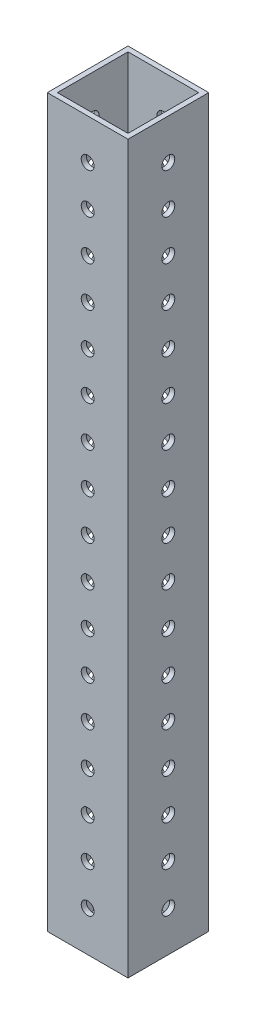
from build123d import *

# Parameters (mm, degrees)
SKETCH1_W           = 25.4
SKETCH1_H           = 25.4
SKETCH1_W_2         = 22.225
SKETCH1_H_2         = 22.225
BOSS_EXTRUDE1_DEPTH = 228.6
SKETCH2_R           = 2.0193
CUT_EXTRUDE1_DEPTH  = 26.4
SKETCH3_R           = 2.0193
CUT_EXTRUDE2_DEPTH  = 26.4


with BuildPart() as part:
    # Sketch1 → Boss-Extrude1 (new body)
    with BuildSketch(Plane(origin=(0, 0, 0), x_dir=(1, 0, 0), z_dir=(0, 1, 0))):
        with Locations((12.7, 12.7)):
            Rectangle(SKETCH1_W, SKETCH1_H)
        with Locations((12.7, 12.7)):
            Rectangle(SKETCH1_W_2, SKETCH1_H_2, mode=Mode.SUBTRACT)
    extrude(amount=BOSS_EXTRUDE1_DEPTH)

    # Sketch2 → Cut-Extrude1 (cut, through all)
    with BuildSketch(Plane.XY):
        with Locations((12.7, 12.7)):
            Circle(SKETCH2_R)
        with Locations((12.7, 25.4)):
            Circle(SKETCH2_R)
        with Locations((12.7, 38.1)):
            Circle(SKETCH2_R)
        with Locations((12.7, 50.8)):
            Circle(SKETCH2_R)
        with Locations((12.7, 63.5)):
            Circle(SKETCH2_R)
        with Locations((12.7, 76.2)):
            Circle(SKETCH2_R)
        with Locations((12.7, 88.9)):
            Circle(SKETCH2_R)
        with Locations((12.7, 101.6)):
            Circle(SKETCH2_R)
        with Locations((12.7, 114.3)):
            Circle(SKETCH2_R)
        with Locations((12.7, 127)):
            Circle(SKETCH2_R)
        with Locations((12.7, 139.7)):
            Circle(SKETCH2_R)
        with Locations((12.7, 152.4)):
            Circle(SKETCH2_R)
        with Locations((12.7, 165.1)):
            Circle(SKETCH2_R)
        with Locations((12.7, 177.8)):
            Circle(SKETCH2_R)
        with Locations((12.7, 190.5)):
            Circle(SKETCH2_R)
        with Locations((12.7, 203.2)):
            Circle(SKETCH2_R)
        with Locations((12.7, 215.9)):
            Circle(SKETCH2_R)
    extrude(amount=-CUT_EXTRUDE1_DEPTH, mode=Mode.SUBTRACT)

    # Sketch3 → Cut-Extrude2 (cut, through all)
    with BuildSketch(Plane(origin=(25.4, 0, 0), x_dir=(0, 0, -1), z_dir=(1, 0, 0))):
        with Locations((12.7, 12.7)):
            Circle(SKETCH3_R)
        with Locations((12.7, 25.4)):
            Circle(SKETCH3_R)
        with Locations((12.7, 38.1)):
            Circle(SKETCH3_R)
        with Locations((12.7, 50.8)):
            Circle(SKETCH3_R)
        with Locations((12.7, 63.5)):
            Circle(SKETCH3_R)
        with Locations((12.7, 76.2)):
            Circle(SKETCH3_R)
        with Locations((12.7, 88.9)):
            Circle(SKETCH3_R)
        with Locations((12.7, 101.6)):
            Circle(SKETCH3_R)
        with Locations((12.7, 114.3)):
            Circle(SKETCH3_R)
        with Locations((12.7, 127)):
            Circle(SKETCH3_R)
        with Locations((12.7, 139.7)):
            Circle(SKETCH3_R)
        with Locations((12.7, 152.4)):
            Circle(SKETCH3_R)
        with Locations((12.7, 165.1)):
            Circle(SKETCH3_R)
        with Locations((12.7, 177.8)):
            Circle(SKETCH3_R)
        with Locations((12.7, 190.5)):
            Circle(SKETCH3_R)
        with Locations((12.7, 203.2)):
            Circle(SKETCH3_R)
        with Locations((12.7, 215.9)):
            Circle(SKETCH3_R)
    extrude(amount=-CUT_EXTRUDE2_DEPTH, mode=Mode.SUBTRACT)


solid = part.part
